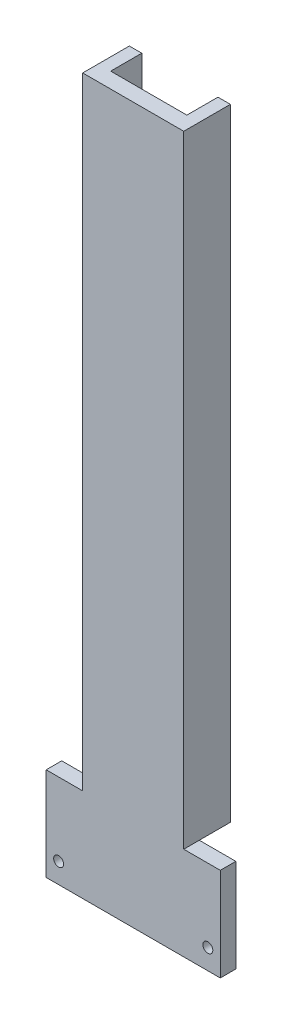
from build123d import *

# Parameters (mm, degrees)
BOSS_EXTRUDE1_DEPTH            = 200
BOSS_EXTRUDE2_DEPTH            = 5
M3_CLEARANCE_HOLE1_D           = 3.2
M3_CLEARANCE_HOLE1_CSINK_D     = 3.25
M3_CLEARANCE_HOLE1_CSINK_ANGLE = 90


with BuildPart() as part:
    # Sketch1 → Boss-Extrude1 (new body)
    with BuildSketch(Plane(origin=(0, 0, 0), x_dir=(1, 0, 0), z_dir=(0, 1, 0))):
        Polygon((0, 0), (0, -15), (32.5, -15), (32.5, 0), (28.5, 0), (28.5, -10), (4, -10), (4, 0), align=None)
    extrude(amount=BOSS_EXTRUDE1_DEPTH)

    # Sketch2 → Boss-Extrude2 (add)
    with BuildSketch(Plane.XY.offset(15)):
        Polygon((32.5, 0), (44.25, 0), (44.25, -30), (-11.75, -30), (-11.75, 0), (0, 0), align=None)
    extrude(amount=-BOSS_EXTRUDE2_DEPTH)

    # M3 Clearance Hole1 (through all)
    with Locations(Plane(origin=(0, 0, 10), x_dir=(-1, 0, 0), z_dir=(0, 0, -1))):
        with Locations((7.75, -23.5), (-40.25, -23.5)):
            CounterSinkHole(M3_CLEARANCE_HOLE1_D / 2, M3_CLEARANCE_HOLE1_CSINK_D / 2, counter_sink_angle=M3_CLEARANCE_HOLE1_CSINK_ANGLE)


solid = part.part
